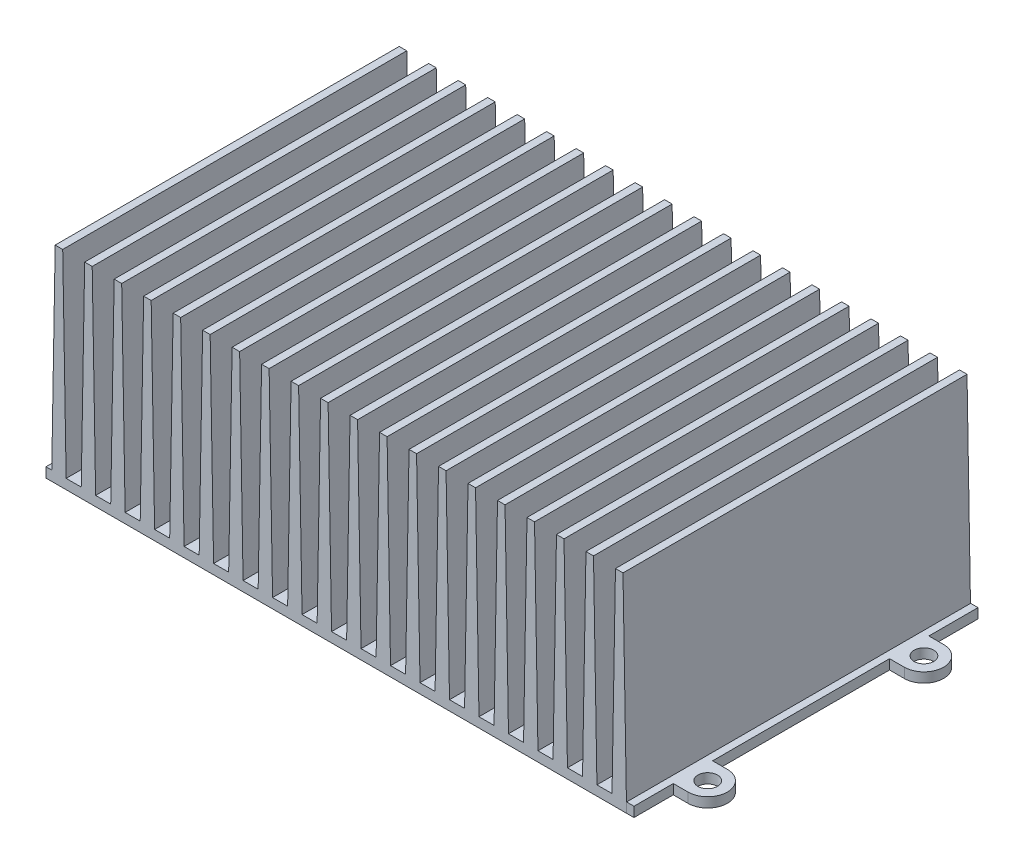
from build123d import *

# Parameters (mm, degrees)
BOSS_EXTRUDE2_DEPTH = 1778
LPATTERN3_COUNT     = 19
LPATTERN3_PITCH     = 152.4
SKETCH3_W           = 38.1
SKETCH3_H           = 1778
BOSS_EXTRUDE3_DEPTH = 50.8
BOSS_EXTRUDE5_DEPTH = 50.8
LPATTERN4_COUNT     = 2
LPATTERN4_PITCH     = 1117.6
SKETCH5_R           = 50.8
BOSS_EXTRUDE6_DEPTH = 50.8
LPATTERN5_COUNT     = 2
LPATTERN5_PITCH     = 1117.6


with BuildPart() as part:
    # Sketch1 → Boss-Extrude2 (new body)
    with BuildSketch(Plane.XY):
        Polygon((-152.4, 50.8), (-153.286717298, 50.8), (-171.021063265, 1066.8), (-209.978936735, 1066.8), (-228.6, 0), (-152.4, 0), (-76.2, 0), (0, 0), (-18.621063265, 1066.8), (-57.578936735, 1066.8), (-75.313282702, 50.8), (-76.2, 50.8), align=None)
    boss_extrude2 = extrude(amount=BOSS_EXTRUDE2_DEPTH)

    # LPattern3: Boss-Extrude2 ×19
    with Locations(*[(-i * LPATTERN3_PITCH, 0, 0) for i in range(1, LPATTERN3_COUNT)]):
        add(boss_extrude2)

    # Sketch3 → Boss-Extrude3 (add)
    with BuildSketch(Plane(origin=(0, 0, 0), x_dir=(1, 0, 0), z_dir=(0, 1, 0))):
        with Locations((19.05, -889)):
            Rectangle(SKETCH3_W, SKETCH3_H)
        with Locations((-2981.539468367, -889)):
            Rectangle(SKETCH3_W, SKETCH3_H)
    extrude(amount=BOSS_EXTRUDE3_DEPTH)

    # Sketch4 → Boss-Extrude5 (add)
    with BuildSketch(Plane(origin=(0, 50.8, 0), x_dir=(1, 0, 0), z_dir=(0, 1, 0))):
        with BuildLine():
            Line((38.1, -1473.2), (38.1, -1574.8))
            Line((38.1, -1574.8), (114.3, -1574.8))
            ThreePointArc((114.3, -1574.8), (215.9, -1473.2), (114.3, -1371.6))
            Line((114.3, -1371.6), (38.1, -1371.6))
            Line((38.1, -1371.6), (38.1, -1473.2))
        make_face()
        with BuildLine():
            ThreePointArc((165.1, -1473.2), (114.3, -1524), (63.5, -1473.2))
            ThreePointArc((63.5, -1473.2), (114.3, -1422.4), (165.1, -1473.2))
        make_face(mode=Mode.SUBTRACT)
    boss_extrude5 = extrude(amount=-BOSS_EXTRUDE5_DEPTH)

    # LPattern4: Boss-Extrude5 ×2
    with Locations(*[(0, 0, -i * LPATTERN4_PITCH) for i in range(1, LPATTERN4_COUNT)]):
        add(boss_extrude5)

    # Sketch5 → Boss-Extrude6 (add)
    with BuildSketch(Plane(origin=(0, 50.8, 0), x_dir=(1, 0, 0), z_dir=(0, 1, 0))):
        with BuildLine():
            Line((-3076.789468367, -1574.8), (-3000.589468367, -1574.8))
            Line((-3000.589468367, -1574.8), (-3000.589468367, -1473.2))
            Line((-3000.589468367, -1473.2), (-3000.589468367, -1371.6))
            Line((-3000.589468367, -1371.6), (-3076.789468367, -1371.6))
            ThreePointArc((-3076.789468367, -1371.6), (-3178.389468367, -1473.2), (-3076.789468367, -1574.8))
        make_face()
        with Locations((-3076.789468367, -1473.2)):
            Circle(SKETCH5_R, mode=Mode.SUBTRACT)
    boss_extrude6 = extrude(amount=-BOSS_EXTRUDE6_DEPTH)

    # LPattern5: Boss-Extrude6 ×2
    with Locations(*[(0, 0, -i * LPATTERN5_PITCH) for i in range(1, LPATTERN5_COUNT)]):
        add(boss_extrude6)


solid = part.part
